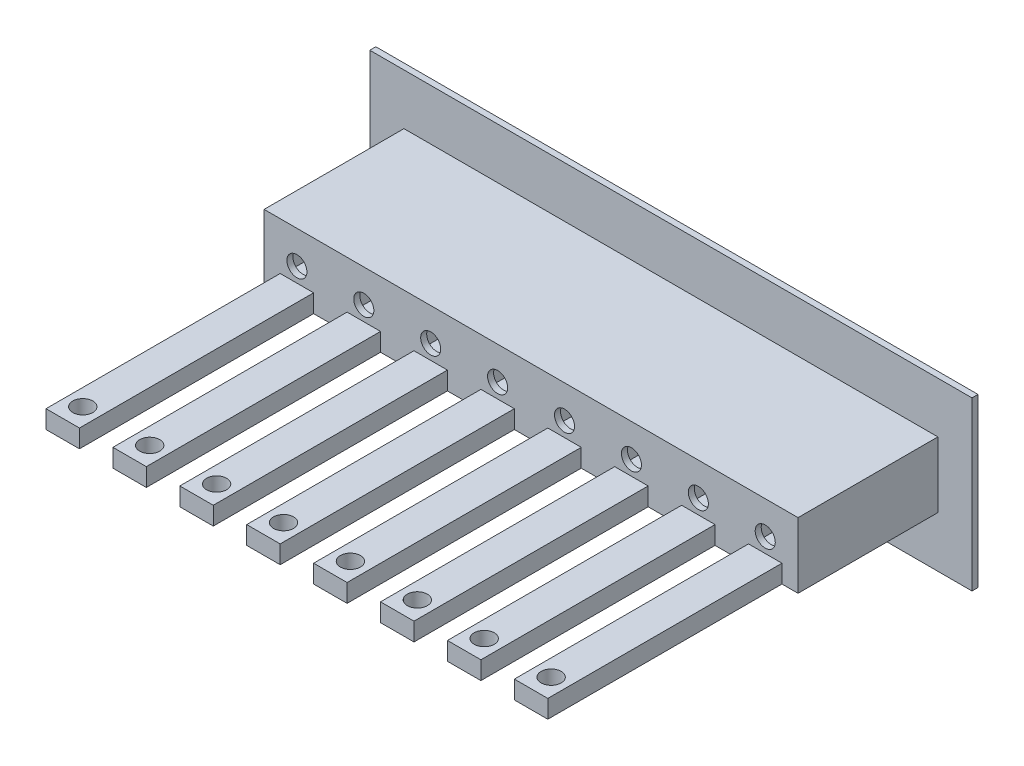
from build123d import *

# Parameters (mm, degrees)
CROQUIS1_W              = 90
CROQUIS1_H              = 25
SALIENTE_EXTRUIR1_DEPTH = 0.9
CROQUIS2_W              = 8
CROQUIS2_H              = 8
CORTAR_EXTRUIR1_DEPTH   = 0.9
CROQUIS3_W              = 79.8
CROQUIS3_H              = 9.8
CROQUIS3_W_2            = 8
CROQUIS3_H_2            = 8
SALIENTE_EXTRUIR2_DEPTH = 20
CROQUIS4_W              = 79.8
CROQUIS4_H              = 9.8
CROQUIS4_R              = 1.5
SALIENTE_EXTRUIR3_DEPTH = 0.9
CROQUIS5_W              = 5
CROQUIS5_H              = 35
CROQUIS5_R              = 1.5
SALIENTE_EXTRUIR4_DEPTH = 2.7


with BuildPart() as part:
    # Croquis1 → Saliente-Extruir1 (new body)
    with BuildSketch(Plane.XY):
        with Locations((-47.428766378, 9.852941176)):
            Rectangle(CROQUIS1_W, CROQUIS1_H)
    extrude(amount=SALIENTE_EXTRUIR1_DEPTH)

    # Croquis2 → Cortar-Extruir1 (cut)
    with BuildSketch(Plane.XY.offset(0.9)):
        with Locations((-82.428766378, 9.852941176)):
            Rectangle(CROQUIS2_W, CROQUIS2_H)
        with Locations((-72.428766378, 9.852941176)):
            Rectangle(CROQUIS2_W, CROQUIS2_H)
        with Locations((-62.428766378, 9.852941176)):
            Rectangle(CROQUIS2_W, CROQUIS2_H)
        with Locations((-52.428766378, 9.852941176)):
            Rectangle(CROQUIS2_W, CROQUIS2_H)
        with Locations((-42.428766378, 9.852941176)):
            Rectangle(CROQUIS2_W, CROQUIS2_H)
        with Locations((-32.428766378, 9.852941176)):
            Rectangle(CROQUIS2_W, CROQUIS2_H)
        with Locations((-22.428766378, 9.852941176)):
            Rectangle(CROQUIS2_W, CROQUIS2_H)
        with Locations((-12.428766378, 9.852941176)):
            Rectangle(CROQUIS2_W, CROQUIS2_H)
    extrude(amount=-CORTAR_EXTRUIR1_DEPTH, mode=Mode.SUBTRACT)

    # Croquis3 → Saliente-Extruir2 (add)
    with BuildSketch(Plane.XY.offset(0.9)):
        with Locations((-47.428766378, 9.852941176)):
            Rectangle(CROQUIS3_W, CROQUIS3_H)
        with Locations((-72.428766378, 9.852941176)):
            Rectangle(CROQUIS3_W_2, CROQUIS3_H_2, mode=Mode.SUBTRACT)
        with Locations((-82.428766378, 9.852941176)):
            Rectangle(CROQUIS3_W_2, CROQUIS3_H_2, mode=Mode.SUBTRACT)
        with Locations((-62.428766378, 9.852941176)):
            Rectangle(CROQUIS3_W_2, CROQUIS3_H_2, mode=Mode.SUBTRACT)
        with Locations((-52.428766378, 9.852941176)):
            Rectangle(CROQUIS3_W_2, CROQUIS3_H_2, mode=Mode.SUBTRACT)
        with Locations((-42.428766378, 9.852941176)):
            Rectangle(CROQUIS3_W_2, CROQUIS3_H_2, mode=Mode.SUBTRACT)
        with Locations((-32.428766378, 9.852941176)):
            Rectangle(CROQUIS3_W_2, CROQUIS3_H_2, mode=Mode.SUBTRACT)
        with Locations((-22.428766378, 9.852941176)):
            Rectangle(CROQUIS3_W_2, CROQUIS3_H_2, mode=Mode.SUBTRACT)
        with Locations((-12.428766378, 9.852941176)):
            Rectangle(CROQUIS3_W_2, CROQUIS3_H_2, mode=Mode.SUBTRACT)
    extrude(amount=SALIENTE_EXTRUIR2_DEPTH)

    # Croquis4 → Saliente-Extruir3 (add)
    with BuildSketch(Plane.XY.offset(20.9)):
        with Locations((-47.428766378, 9.852941176)):
            Rectangle(CROQUIS4_W, CROQUIS4_H)
        with Locations((-82.428766378, 9.852941176)):
            Circle(CROQUIS4_R, mode=Mode.SUBTRACT)
        with Locations((-72.428766378, 9.852941176)):
            Circle(CROQUIS4_R, mode=Mode.SUBTRACT)
        with Locations((-62.428766378, 9.852941176)):
            Circle(CROQUIS4_R, mode=Mode.SUBTRACT)
        with Locations((-52.428766378, 9.852941176)):
            Circle(CROQUIS4_R, mode=Mode.SUBTRACT)
        with Locations((-42.428766378, 9.852941176)):
            Circle(CROQUIS4_R, mode=Mode.SUBTRACT)
        with Locations((-32.428766378, 9.852941176)):
            Circle(CROQUIS4_R, mode=Mode.SUBTRACT)
        with Locations((-22.428766378, 9.852941176)):
            Circle(CROQUIS4_R, mode=Mode.SUBTRACT)
        with Locations((-12.428766378, 9.852941176)):
            Circle(CROQUIS4_R, mode=Mode.SUBTRACT)
    extrude(amount=SALIENTE_EXTRUIR3_DEPTH)

    # Croquis5 → Saliente-Extruir4 (add)
    with BuildSketch(Plane.XZ.offset(-4.952941176)):
        with Locations((-82.428766378, 39.3)):
            Rectangle(CROQUIS5_W, CROQUIS5_H)
        with Locations((-82.428766378, 53.8)):
            Circle(CROQUIS5_R, mode=Mode.SUBTRACT)
        with Locations((-72.428766378, 39.3)):
            Rectangle(CROQUIS5_W, CROQUIS5_H)
        with Locations((-72.428766378, 53.8)):
            Circle(CROQUIS5_R, mode=Mode.SUBTRACT)
        with Locations((-62.428766378, 39.3)):
            Rectangle(CROQUIS5_W, CROQUIS5_H)
        with Locations((-62.428766378, 53.8)):
            Circle(CROQUIS5_R, mode=Mode.SUBTRACT)
        with Locations((-52.428766378, 39.3)):
            Rectangle(CROQUIS5_W, CROQUIS5_H)
        with Locations((-52.428766378, 53.8)):
            Circle(CROQUIS5_R, mode=Mode.SUBTRACT)
        with Locations((-42.428766378, 39.3)):
            Rectangle(CROQUIS5_W, CROQUIS5_H)
        with Locations((-42.428766378, 53.8)):
            Circle(CROQUIS5_R, mode=Mode.SUBTRACT)
        with Locations((-32.428766378, 39.3)):
            Rectangle(CROQUIS5_W, CROQUIS5_H)
        with Locations((-32.428766378, 53.8)):
            Circle(CROQUIS5_R, mode=Mode.SUBTRACT)
        with Locations((-22.428766378, 39.3)):
            Rectangle(CROQUIS5_W, CROQUIS5_H)
        with Locations((-22.428766378, 53.8)):
            Circle(CROQUIS5_R, mode=Mode.SUBTRACT)
        with Locations((-12.428766378, 39.3)):
            Rectangle(CROQUIS5_W, CROQUIS5_H)
        with Locations((-12.428766378, 53.8)):
            Circle(CROQUIS5_R, mode=Mode.SUBTRACT)
    extrude(amount=-SALIENTE_EXTRUIR4_DEPTH)


solid = part.part
